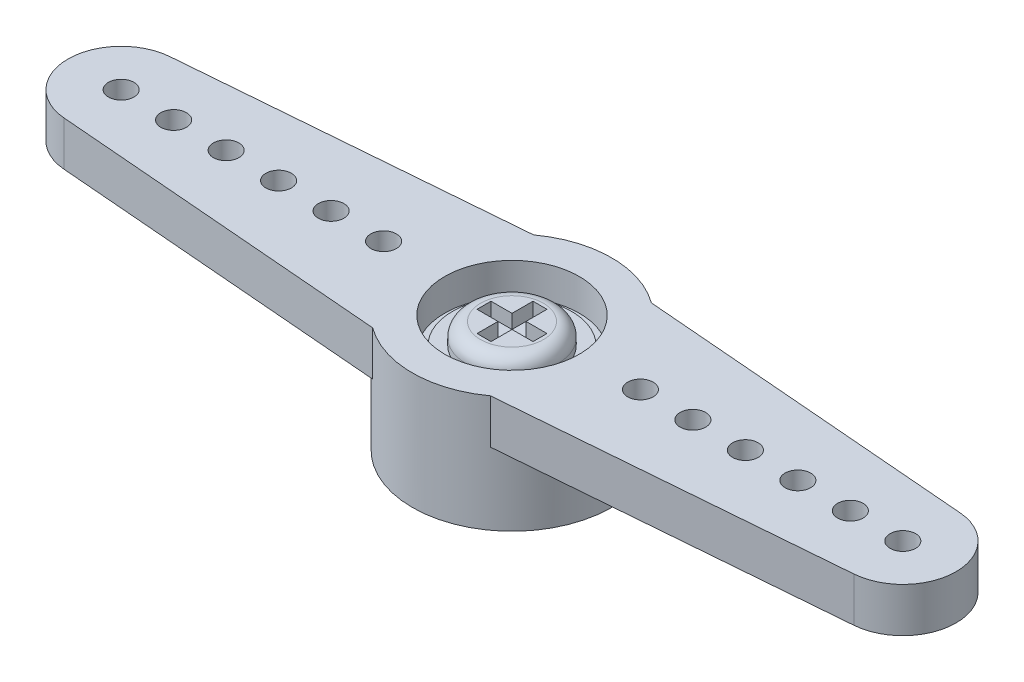
from build123d import *
from build123d.topology import SkipClean

# Parameters (mm, degrees)
EXTRUDE17_DEPTH = 1.6129
SKETCH19_R      = 3.6195
EXTRUDE19_DEPTH = 4.2291
SKETCH20_R      = 0.46355
SKETCH20_R_2    = 1.27
EXTRUDE20_DEPTH = 18.050548
SKETCH21_R      = 2.44475
EXTRUDE21_DEPTH = 1.1557
SKETCH22_R      = 2.286
EXTRUDE22_DEPTH = 2.3368
SKETCH23_R      = 2.159
EXTRUDE23_DEPTH = 0.2032
SKETCH24_R      = 1.651
EXTRUDE24_DEPTH = 0.762
EXTRUDE25_DEPTH = 0.508
FILLET1_R       = 0.508


with BuildPart() as part:
    # Sketch18 → Extrude17 (new body)
    with BuildSketch(Plane(origin=(0, 0, 0), x_dir=(1, 0, 0), z_dir=(0, 1, 0))):
        with BuildLine():
            Line((-14.34306, 1.923992), (-2.137414, 2.921))
            ThreePointArc((-2.137414, 2.921), (0, 3.6195), (2.137414, 2.921))
            Line((2.137414, 2.921), (14.34306, 1.923992))
            ThreePointArc((14.34306, 1.923992), (16.1163, 0), (14.34306, -1.923992))
            Line((14.34306, -1.923992), (2.137414, -2.921))
            ThreePointArc((2.137414, -2.921), (0, -3.6195), (-2.137414, -2.921))
            Line((-2.137414, -2.921), (-14.34306, -1.923992))
            ThreePointArc((-14.34306, -1.923992), (-16.1163, 0), (-14.34306, 1.923992))
        make_face()
    extrude(amount=EXTRUDE17_DEPTH)

    # Sketch19 → Extrude19 (add)
    with SkipClean():  # the faces are left unmerged after this step: merging them gives an invalid solid
        with BuildSketch(Plane(origin=(0, 1.6129, 0), x_dir=(1, 0, 0), z_dir=(0, 1, 0))):
            with Locations(Location((0, 0, 0), (0, 0, 53.805553))):
                Circle(SKETCH19_R)
        extrude(amount=-EXTRUDE19_DEPTH)

    # Sketch20 → Extrude20 (cut, through all)
    with SkipClean():  # the faces are left unmerged after this step: merging them gives an invalid solid
        with BuildSketch(Plane(origin=(0, 1.6129, 0), x_dir=(1, 0, 0), z_dir=(0, 1, 0))):
            with Locations(Location((-14.1859, 0, 0), (0, 0, 270))):
                Circle(SKETCH20_R)
            with Locations(Location((0, 0, 0), (0, 0, 270))):
                Circle(SKETCH20_R_2)
            with Locations(Location((12.2809, 0, 0), (0, 0, 270))):
                Circle(SKETCH20_R)
            with Locations(Location((-4.6609, 0, 0), (0, 0, 270))):
                Circle(SKETCH20_R)
            with Locations(Location((-6.5659, 0, 0), (0, 0, 270))):
                Circle(SKETCH20_R)
            with Locations(Location((-8.4709, 0, 0), (0, 0, 270))):
                Circle(SKETCH20_R)
            with Locations(Location((-10.3759, 0, 0), (0, 0, 270))):
                Circle(SKETCH20_R)
            with Locations(Location((-12.2809, 0, 0), (0, 0, 270))):
                Circle(SKETCH20_R)
            with Locations(Location((10.3759, 0, 0), (0, 0, 270))):
                Circle(SKETCH20_R)
            with Locations(Location((8.4709, 0, 0), (0, 0, 270))):
                Circle(SKETCH20_R)
            with Locations(Location((6.5659, 0, 0), (0, 0, 270))):
                Circle(SKETCH20_R)
            with Locations(Location((4.6609, 0, 0), (0, 0, 270))):
                Circle(SKETCH20_R)
            with Locations(Location((14.1859, 0, 0), (0, 0, 270))):
                Circle(SKETCH20_R)
        extrude(amount=-EXTRUDE20_DEPTH, mode=Mode.SUBTRACT)

    # Sketch21 → Extrude21 (cut)
    with SkipClean():  # the faces are left unmerged after this step: merging them gives an invalid solid
        with BuildSketch(Plane(origin=(0, 1.6129, 0), x_dir=(1, 0, 0), z_dir=(0, 1, 0))):
            with Locations(Location((0, 0, 0), (0, 0, 270))):
                Circle(SKETCH21_R)
        extrude(amount=-EXTRUDE21_DEPTH, mode=Mode.SUBTRACT)

    # Sketch22 → Extrude22 (cut)
    with SkipClean():  # the faces are left unmerged after this step: merging them gives an invalid solid
        with BuildSketch(Plane.XZ.offset(2.6162)):
            with Locations(Location((0, 0, 0), (0, 0, 270))):
                Circle(SKETCH22_R)
        extrude(amount=-EXTRUDE22_DEPTH, mode=Mode.SUBTRACT)



with BuildPart() as body_2:
    # Sketch23 → Extrude23 (new body)
    with BuildSketch(Plane(origin=(0, 0.4572, 0), x_dir=(1, 0, 0), z_dir=(0, 1, 0))):
        with Locations(Location((0, 0, 0), (0, 0, 270))):
            Circle(SKETCH23_R)
    extrude(amount=EXTRUDE23_DEPTH)


with BuildPart() as part_1:
    with SkipClean():  # the faces are left unmerged after this step: merging them gives an invalid solid
        add(part.part)

        add(body_2.part)  # Extrude24 merges body 2
        # Sketch24 → Extrude24 (add)
        with BuildSketch(Plane(origin=(0, 0.6604, 0), x_dir=(1, 0, 0), z_dir=(0, 1, 0))):
            with Locations(Location((0, 0, 0), (0, 0, 90))):
                Circle(SKETCH24_R)
        extrude(amount=EXTRUDE24_DEPTH)

    # Sketch25 → Extrude25 (cut)
    with SkipClean():  # the faces are left unmerged after this step: merging them gives an invalid solid
        with BuildSketch(Plane(origin=(0, 1.4224, 0), x_dir=(1, 0, 0), z_dir=(0, 1, 0))):
            Polygon((0.254, -1.016), (-0.254, -1.016), (-0.254, -0.254), (-1.016, -0.254), (-1.016, 0.254), (-0.254, 0.254), (-0.254, 1.016), (0.254, 1.016), (0.254, 0.254), (1.016, 0.254), (1.016, -0.254), (0.254, -0.254), align=None)
        extrude(amount=-EXTRUDE25_DEPTH, mode=Mode.SUBTRACT)

    # Fillet1
    fillet1_edges = [part_1.edges().sort_by_distance(p)[0] for p in [
        (0, 1.4224, 1.651),
    ]]
    fillet(fillet1_edges, radius=FILLET1_R)


solid = part_1.part
